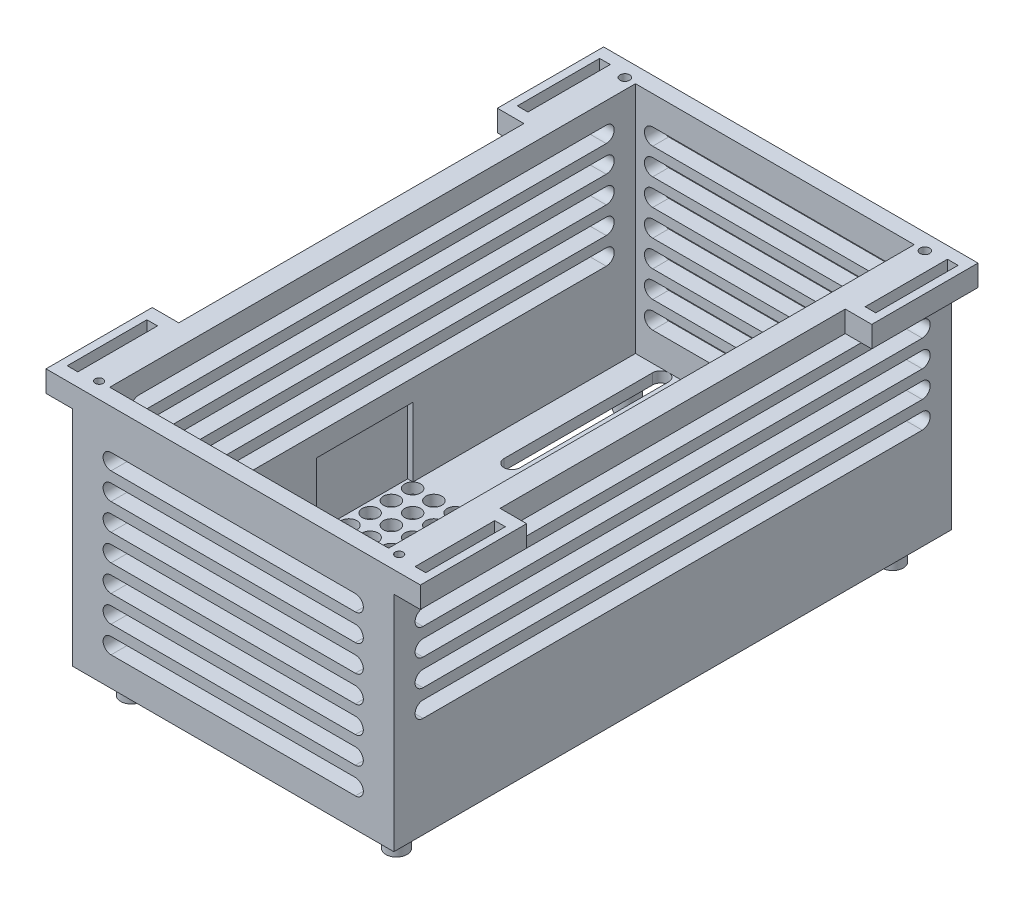
from build123d import *

# Parameters (mm, degrees)
SKETCH3_W            = 4
SKETCH3_H            = 3
SKETCH3_W_2          = 52.5
SKETCH3_H_2          = 102
BOSS_EXTRUDE1_DEPTH  = 46
SKETCH4_W            = 60.5
SKETCH4_H            = 105
BOSS_EXTRUDE2_DEPTH  = 2
SKETCH5_W            = 41
SKETCH5_H            = 42
CUT_EXTRUDE1_DEPTH   = 15
SKETCH6_R            = 1.5
CUT_EXTRUDE4_DEPTH   = 15
CUT_EXTRUDE15_DEPTH  = 15
CUT_EXTRUDE16_DEPTH  = 15
CUT_EXTRUDE17_DEPTH  = 15
CUT_EXTRUDE20_DEPTH  = 15
SKETCH22_W           = 60.5
SKETCH22_H           = 46
BOSS_EXTRUDE3_DEPTH  = 3
CUT_EXTRUDE21_DEPTH  = 23
SKETCH26_R           = 0.9
CUT_EXTRUDE22_DEPTH  = 4
SKETCH27_R           = 0.75
CUT_EXTRUDE23_DEPTH  = 4
SKETCH29_W           = 18.192452435
SKETCH29_H           = 13
CUT_EXTRUDE24_DEPTH  = 1
SKETCH38_W           = 20
SKETCH38_H           = 4.012028652
BOSS_EXTRUDE10_DEPTH = 5
SKETCH39_W           = 20
SKETCH39_H           = 4
BOSS_EXTRUDE11_DEPTH = 5
SKETCH41_W           = 2
SKETCH41_H           = 15
CUT_EXTRUDE25_DEPTH  = 5
SKETCH42_W           = 2
SKETCH42_H           = 15.5
CUT_EXTRUDE26_DEPTH  = 5
SKETCH43_R           = 2
BOSS_EXTRUDE13_DEPTH = 5


with BuildPart() as part:
    # Sketch3 → Boss-Extrude1 (new body)
    with BuildSketch(Plane(origin=(0, 0, 0), x_dir=(1, 0, 0), z_dir=(0, 1, 0))):
        with Locations((28.25, 51)):
            Rectangle(SKETCH3_W, SKETCH3_H)
        with Locations((0, 51)):
            Rectangle(SKETCH3_W_2, SKETCH3_H)
        with Locations((28.25, -1.5)):
            Rectangle(SKETCH3_W, SKETCH3_H_2)
        with Locations((-28.25, 51)):
            Rectangle(SKETCH3_W, SKETCH3_H)
        with Locations((-28.25, -1.5)):
            Rectangle(SKETCH3_W, SKETCH3_H_2)
    extrude(amount=BOSS_EXTRUDE1_DEPTH)

    # Sketch4 → Boss-Extrude2 (add)
    with BuildSketch(Plane(origin=(0, 0, 0), x_dir=(1, 0, 0), z_dir=(0, 1, 0))):
        Rectangle(SKETCH4_W, SKETCH4_H)
    extrude(amount=BOSS_EXTRUDE2_DEPTH)

    # Sketch5 → Cut-Extrude1 (cut)
    with BuildSketch(Plane(origin=(0, 0, 0), x_dir=(1, 0, 0), z_dir=(0, 1, 0))):
        with Locations((6.75, -10.5)):
            Rectangle(SKETCH5_W, SKETCH5_H)
    extrude(amount=CUT_EXTRUDE1_DEPTH, mode=Mode.SUBTRACT)

    # Sketch6 → Cut-Extrude4 (cut)
    with BuildSketch(Plane(origin=(0, 0, 0), x_dir=(1, 0, 0), z_dir=(0, 1, 0))):
        with Locations((-17.226140596, -1.489137384)):
            Circle(SKETCH6_R)
        with Locations((-17.226140596, -5.489137384)):
            Circle(SKETCH6_R)
        with Locations((-17.226140596, -9.489137384)):
            Circle(SKETCH6_R)
        with Locations((-17.226140596, 2.510862616)):
            Circle(SKETCH6_R)
        with Locations((-17.226140596, 6.510862616)):
            Circle(SKETCH6_R)
        with Locations((-21.226140596, -9.489137384)):
            Circle(SKETCH6_R)
        with Locations((-21.226140596, -5.489137384)):
            Circle(SKETCH6_R)
        with Locations((-21.226140596, -1.489137384)):
            Circle(SKETCH6_R)
        with Locations((-21.226140596, 2.510862616)):
            Circle(SKETCH6_R)
        with Locations((-21.226140596, 6.510862616)):
            Circle(SKETCH6_R)
        with Locations((-25.226140596, -9.489137384)):
            Circle(SKETCH6_R)
        with Locations((-25.226140596, -5.489137384)):
            Circle(SKETCH6_R)
        with Locations((-25.226140596, -1.489137384)):
            Circle(SKETCH6_R)
        with Locations((-25.226140596, 2.510862616)):
            Circle(SKETCH6_R)
        with Locations((-25.226140596, 6.510862616)):
            Circle(SKETCH6_R)
    extrude(amount=CUT_EXTRUDE4_DEPTH, mode=Mode.SUBTRACT)

    # Sketch15 → Cut-Extrude15 (cut)
    with BuildSketch(Plane.XZ):
        with BuildLine():
            Line((1.5, -20), (1.5, -48))
            ThreePointArc((1.5, -48), (0, -49.5), (-1.5, -48))
            Line((-1.5, -48), (-1.5, -20))
            ThreePointArc((-1.5, -20), (0, -18.5), (1.5, -20))
        make_face()
        with BuildLine():
            Line((6.5, -20), (6.5, -48))
            ThreePointArc((6.5, -48), (5, -49.5), (3.5, -48))
            Line((3.5, -48), (3.5, -20))
            ThreePointArc((3.5, -20), (5, -18.5), (6.5, -20))
        make_face()
        with BuildLine():
            Line((11.5, -20), (11.5, -48))
            ThreePointArc((11.5, -48), (10, -49.5), (8.5, -48))
            Line((8.5, -48), (8.5, -20))
            ThreePointArc((8.5, -20), (10, -18.5), (11.5, -20))
        make_face()
        with BuildLine():
            Line((16.5, -20), (16.5, -48))
            ThreePointArc((16.5, -48), (15, -49.5), (13.5, -48))
            Line((13.5, -48), (13.5, -20))
            ThreePointArc((13.5, -20), (15, -18.5), (16.5, -20))
        make_face()
        with BuildLine():
            Line((21.5, -20), (21.5, -48))
            ThreePointArc((21.5, -48), (20, -49.5), (18.5, -48))
            Line((18.5, -48), (18.5, -20))
            ThreePointArc((18.5, -20), (20, -18.5), (21.5, -20))
        make_face()
        with BuildLine():
            Line((-3.5, -20), (-3.5, -48))
            ThreePointArc((-3.5, -48), (-5, -49.5), (-6.5, -48))
            Line((-6.5, -48), (-6.5, -20))
            ThreePointArc((-6.5, -20), (-5, -18.5), (-3.5, -20))
        make_face()
        with BuildLine():
            Line((-8.5, -20), (-8.5, -48))
            ThreePointArc((-8.5, -48), (-10, -49.5), (-11.5, -48))
            Line((-11.5, -48), (-11.5, -20))
            ThreePointArc((-11.5, -20), (-10, -18.5), (-8.5, -20))
        make_face()
        with BuildLine():
            Line((-13.5, -20), (-13.5, -48))
            ThreePointArc((-13.5, -48), (-15, -49.5), (-16.5, -48))
            Line((-16.5, -48), (-16.5, -20))
            ThreePointArc((-16.5, -20), (-15, -18.5), (-13.5, -20))
        make_face()
        with BuildLine():
            Line((-18.5, -20), (-18.5, -48))
            ThreePointArc((-18.5, -48), (-20, -49.5), (-21.5, -48))
            Line((-21.5, -48), (-21.5, -20))
            ThreePointArc((-21.5, -20), (-20, -18.5), (-18.5, -20))
        make_face()
    extrude(amount=-CUT_EXTRUDE15_DEPTH, mode=Mode.SUBTRACT)

    # Sketch16 → Cut-Extrude16 (cut)
    with BuildSketch(Plane.ZY.offset(30.25)):
        with BuildLine():
            Line((-44, 41.987971348), (44, 41.987971348))
            ThreePointArc((44, 41.987971348), (45.5, 40.487971348), (44, 38.987971348))
            Line((44, 38.987971348), (-44, 38.987971348))
            ThreePointArc((-44, 38.987971348), (-45.5, 40.487971348), (-44, 41.987971348))
        make_face()
        with BuildLine():
            Line((-44, 36.987971348), (44, 36.987971348))
            ThreePointArc((44, 36.987971348), (45.5, 35.487971348), (44, 33.987971348))
            Line((44, 33.987971348), (-44, 33.987971348))
            ThreePointArc((-44, 33.987971348), (-45.5, 35.487971348), (-44, 36.987971348))
        make_face()
        with BuildLine():
            Line((-44, 31.987971348), (44, 31.987971348))
            ThreePointArc((44, 31.987971348), (45.5, 30.487971348), (44, 28.987971348))
            Line((44, 28.987971348), (-44, 28.987971348))
            ThreePointArc((-44, 28.987971348), (-45.5, 30.487971348), (-44, 31.987971348))
        make_face()
        with BuildLine():
            Line((-44, 26.987971348), (44, 26.987971348))
            ThreePointArc((44, 26.987971348), (45.5, 25.487971348), (44, 23.987971348))
            Line((44, 23.987971348), (-44, 23.987971348))
            ThreePointArc((-44, 23.987971348), (-45.5, 25.487971348), (-44, 26.987971348))
        make_face()
        with BuildLine():
            Line((-44, 21.987971348), (44, 21.987971348))
            ThreePointArc((44, 21.987971348), (45.5, 20.487971348), (44, 18.987971348))
            Line((44, 18.987971348), (-44, 18.987971348))
            ThreePointArc((-44, 18.987971348), (-45.5, 20.487971348), (-44, 21.987971348))
        make_face()
    extrude(amount=-CUT_EXTRUDE16_DEPTH, mode=Mode.SUBTRACT)

    # Sketch20 → Cut-Extrude17 (cut)
    with BuildSketch(Plane(origin=(30.25, 0, 0), x_dir=(0, 0, -1), z_dir=(1, 0, 0))):
        with BuildLine():
            Line((-47, 42), (47, 42))
            ThreePointArc((47, 42), (48.5, 40.5), (47, 39))
            Line((47, 39), (-47, 39))
            ThreePointArc((-47, 39), (-48.5, 40.5), (-47, 42))
        make_face()
        with BuildLine():
            Line((-47, 37), (47, 37))
            ThreePointArc((47, 37), (48.5, 35.5), (47, 34))
            Line((47, 34), (-47, 34))
            ThreePointArc((-47, 34), (-48.5, 35.5), (-47, 37))
        make_face()
        with BuildLine():
            Line((-47, 32), (47, 32))
            ThreePointArc((47, 32), (48.5, 30.5), (47, 29))
            Line((47, 29), (-47, 29))
            ThreePointArc((-47, 29), (-48.5, 30.5), (-47, 32))
        make_face()
        with BuildLine():
            Line((-47, 27), (47, 27))
            ThreePointArc((47, 27), (48.5, 25.5), (47, 24))
            Line((47, 24), (-47, 24))
            ThreePointArc((-47, 24), (-48.5, 25.5), (-47, 27))
        make_face()
        with BuildLine():
            Line((-47, 22), (47, 22))
            ThreePointArc((47, 22), (48.5, 20.5), (47, 19))
            Line((47, 19), (-47, 19))
            ThreePointArc((-47, 19), (-48.5, 20.5), (-47, 22))
        make_face()
    extrude(amount=-CUT_EXTRUDE17_DEPTH, mode=Mode.SUBTRACT)

    # Sketch21 → Cut-Extrude20 (cut)
    with BuildSketch(Plane(origin=(0, 0, -52.5), x_dir=(-1, 0, 0), z_dir=(0, 0, -1))):
        with BuildLine():
            Line((-23, 25.564715844), (23, 25.564715844))
            ThreePointArc((23, 25.564715844), (24.564715844, 24), (23, 22.435284156))
            Line((23, 22.435284156), (-23, 22.435284156))
            ThreePointArc((-23, 22.435284156), (-24.564715844, 24), (-23, 25.564715844))
        make_face()
        with BuildLine():
            Line((-23, 20.564715844), (23, 20.564715844))
            ThreePointArc((23, 20.564715844), (24.564715844, 19), (23, 17.435284156))
            Line((23, 17.435284156), (-23, 17.435284156))
            ThreePointArc((-23, 17.435284156), (-24.564715844, 19), (-23, 20.564715844))
        make_face()
        with BuildLine():
            Line((-23, 15.564715844), (23, 15.564715844))
            ThreePointArc((23, 15.564715844), (24.564715844, 14), (23, 12.435284156))
            Line((23, 12.435284156), (-23, 12.435284156))
            ThreePointArc((-23, 12.435284156), (-24.564715844, 14), (-23, 15.564715844))
        make_face()
        with BuildLine():
            Line((-23, 10.564715844), (23, 10.564715844))
            ThreePointArc((23, 10.564715844), (24.564715844, 9), (23, 7.435284156))
            Line((23, 7.435284156), (-23, 7.435284156))
            ThreePointArc((-23, 7.435284156), (-24.564715844, 9), (-23, 10.564715844))
        make_face()
        with BuildLine():
            Line((-23, 30.564715844), (23, 30.564715844))
            ThreePointArc((23, 30.564715844), (24.564715844, 29), (23, 27.435284156))
            Line((23, 27.435284156), (-23, 27.435284156))
            ThreePointArc((-23, 27.435284156), (-24.564715844, 29), (-23, 30.564715844))
        make_face()
        with BuildLine():
            Line((-23, 35.564715844), (23, 35.564715844))
            ThreePointArc((23, 35.564715844), (24.564715844, 34), (23, 32.435284156))
            Line((23, 32.435284156), (-23, 32.435284156))
            ThreePointArc((-23, 32.435284156), (-24.564715844, 34), (-23, 35.564715844))
        make_face()
        with BuildLine():
            Line((-23, 40.564715844), (23, 40.564715844))
            ThreePointArc((23, 40.564715844), (24.564715844, 39), (23, 37.435284156))
            Line((23, 37.435284156), (-23, 37.435284156))
            ThreePointArc((-23, 37.435284156), (-24.564715844, 39), (-23, 40.564715844))
        make_face()
    extrude(amount=-CUT_EXTRUDE20_DEPTH, mode=Mode.SUBTRACT)

    # Sketch22 → Boss-Extrude3 (add)
    with BuildSketch(Plane.XY.offset(52.5)):
        with Locations((0, 23)):
            Rectangle(SKETCH22_W, SKETCH22_H)
    extrude(amount=-BOSS_EXTRUDE3_DEPTH)

    # Sketch24 → Cut-Extrude21 (cut)
    with BuildSketch(Plane.XY.offset(52.5)):
        with BuildLine():
            Line((-23, 23.487971348), (23, 23.487971348))
            ThreePointArc((23, 23.487971348), (24.5, 21.987971348), (23, 20.487971348))
            Line((23, 20.487971348), (-23, 20.487971348))
            ThreePointArc((-23, 20.487971348), (-24.5, 21.987971348), (-23, 23.487971348))
        make_face()
        with BuildLine():
            Line((-23, 18.487971348), (23, 18.487971348))
            ThreePointArc((23, 18.487971348), (24.5, 16.987971348), (23, 15.487971348))
            Line((23, 15.487971348), (-23, 15.487971348))
            ThreePointArc((-23, 15.487971348), (-24.5, 16.987971348), (-23, 18.487971348))
        make_face()
        with BuildLine():
            Line((-23, 13.487971348), (23, 13.487971348))
            ThreePointArc((23, 13.487971348), (24.5, 11.987971348), (23, 10.487971348))
            Line((23, 10.487971348), (-23, 10.487971348))
            ThreePointArc((-23, 10.487971348), (-24.5, 11.987971348), (-23, 13.487971348))
        make_face()
        with BuildLine():
            Line((-23, 8.487971348), (23, 8.487971348))
            ThreePointArc((23, 8.487971348), (24.5, 6.987971348), (23, 5.487971348))
            Line((23, 5.487971348), (-23, 5.487971348))
            ThreePointArc((-23, 5.487971348), (-24.5, 6.987971348), (-23, 8.487971348))
        make_face()
        with BuildLine():
            Line((-23, 28.487971348), (23, 28.487971348))
            ThreePointArc((23, 28.487971348), (24.5, 26.987971348), (23, 25.487971348))
            Line((23, 25.487971348), (-23, 25.487971348))
            ThreePointArc((-23, 25.487971348), (-24.5, 26.987971348), (-23, 28.487971348))
        make_face()
        with BuildLine():
            Line((-23, 33.487971348), (23, 33.487971348))
            ThreePointArc((23, 33.487971348), (24.5, 31.987971348), (23, 30.487971348))
            Line((23, 30.487971348), (-23, 30.487971348))
            ThreePointArc((-23, 30.487971348), (-24.5, 31.987971348), (-23, 33.487971348))
        make_face()
        with BuildLine():
            Line((-23, 38.487971348), (23, 38.487971348))
            ThreePointArc((23, 38.487971348), (24.5, 36.987971348), (23, 35.487971348))
            Line((23, 35.487971348), (-23, 35.487971348))
            ThreePointArc((-23, 35.487971348), (-24.5, 36.987971348), (-23, 38.487971348))
        make_face()
    extrude(amount=-CUT_EXTRUDE21_DEPTH, mode=Mode.SUBTRACT)

    # Sketch26 → Cut-Extrude22 (cut)
    with BuildSketch(Plane(origin=(0, 46, 0), x_dir=(1, 0, 0), z_dir=(0, 1, 0))):
        with Locations((28.25, 49.5)):
            Circle(SKETCH26_R)
        with Locations((-28.25, 49.5)):
            Circle(SKETCH26_R)
    extrude(amount=-CUT_EXTRUDE22_DEPTH, mode=Mode.SUBTRACT)

    # Sketch27 → Cut-Extrude23 (cut)
    with BuildSketch(Plane(origin=(0, 46, 0), x_dir=(1, 0, 0), z_dir=(0, 1, 0))):
        with Locations((28.25, -49.5)):
            Circle(SKETCH27_R)
        with Locations((-28.25, -49.5)):
            Circle(SKETCH27_R)
    extrude(amount=-CUT_EXTRUDE23_DEPTH, mode=Mode.SUBTRACT)

    # Sketch29 → Cut-Extrude24 (cut)
    with BuildSketch(Plane(origin=(-26.25, 0, 0), x_dir=(0, 0, -1), z_dir=(1, 0, 0))):
        with Locations((-1.489137384, 8.5)):
            Rectangle(SKETCH29_W, SKETCH29_H)
    extrude(amount=-CUT_EXTRUDE24_DEPTH, mode=Mode.SUBTRACT)

    # Sketch38 → Boss-Extrude10 (add)
    with BuildSketch(Plane.ZY.offset(30.25)):
        with Locations((-42.5, 43.993985674)):
            Rectangle(SKETCH38_W, SKETCH38_H)
        with Locations((42.5, 43.993985674)):
            Rectangle(SKETCH38_W, SKETCH38_H)
    extrude(amount=BOSS_EXTRUDE10_DEPTH)

    # Sketch39 → Boss-Extrude11 (add)
    with BuildSketch(Plane(origin=(30.25, 0, 0), x_dir=(0, 0, -1), z_dir=(1, 0, 0))):
        with Locations((-42.5, 44)):
            Rectangle(SKETCH39_W, SKETCH39_H)
        with Locations((42.5, 44)):
            Rectangle(SKETCH39_W, SKETCH39_H)
    extrude(amount=BOSS_EXTRUDE11_DEPTH)

    # Sketch41 → Cut-Extrude25 (cut)
    with BuildSketch(Plane(origin=(0, 46, 0), x_dir=(1, 0, 0), z_dir=(0, 1, 0))):
        with Locations((-32.75, -42.5)):
            Rectangle(SKETCH41_W, SKETCH41_H)
        with Locations((32.75, -42.5)):
            Rectangle(SKETCH41_W, SKETCH41_H)
    extrude(amount=-CUT_EXTRUDE25_DEPTH, mode=Mode.SUBTRACT)

    # Sketch42 → Cut-Extrude26 (cut)
    with BuildSketch(Plane(origin=(0, 46, 0), x_dir=(1, 0, 0), z_dir=(0, 1, 0))):
        with Locations((-32.75, 42.5)):
            Rectangle(SKETCH42_W, SKETCH42_H)
        with Locations((32.75, 42.5)):
            Rectangle(SKETCH42_W, SKETCH42_H)
    extrude(amount=-CUT_EXTRUDE26_DEPTH, mode=Mode.SUBTRACT)

    # Sketch43 → Boss-Extrude13 (add)
    with BuildSketch(Plane.XZ):
        with Locations((-24.958825033, 46.71913776)):
            Circle(SKETCH43_R)
        with Locations((24.958825033, 46.71913776)):
            Circle(SKETCH43_R)
        with Locations((24.958825033, -46.71913776)):
            Circle(SKETCH43_R)
        with Locations((-24.958825033, -46.71913776)):
            Circle(SKETCH43_R)
    extrude(amount=BOSS_EXTRUDE13_DEPTH)


solid = part.part
